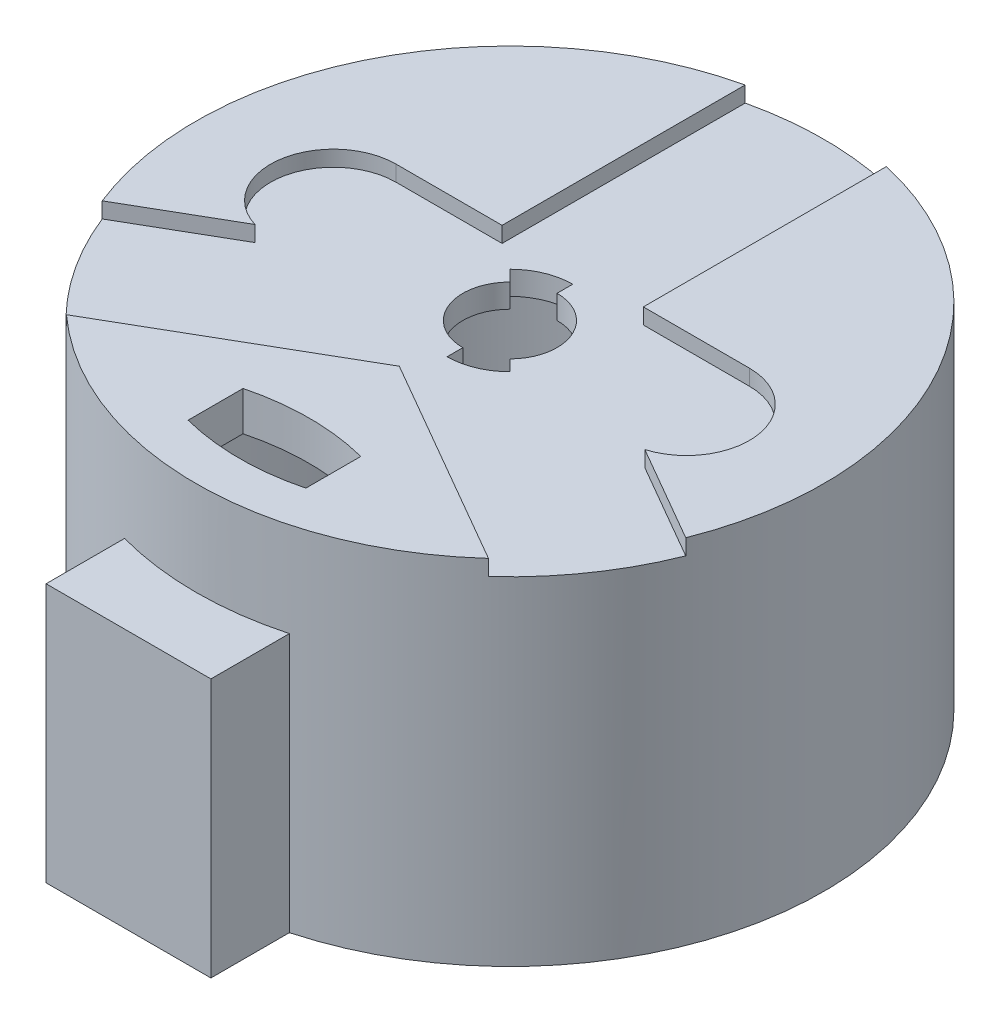
from build123d import *
from build123d.topology import SkipClean

# Parameters (mm, degrees)
BOSS_EXTRUDE1_DEPTH     = 5
BOSS_EXTRUDE1_2_DEPTH   = 5
BOSS_EXTRUDE1_3_DEPTH   = 5
BOSS_EXTRUDE2_DEPTH     = 3
SKETCH2_R               = 40
SKETCH2_R_2             = 35
BOSS_EXTRUDE3_DEPTH     = 40
CUT_EXTRUDE1_DEPTH      = 1
CUT_EXTRUDE1_DEPTH_BACK = 46
SKETCH5_R               = 6
CUT_EXTRUDE4_DEPTH      = 3
CUT_EXTRUDE4_DEPTH_BACK = 44
CUT_EXTRUDE6_DEPTH      = 2
BOSS_EXTRUDE6_DEPTH     = 30
CUT_EXTRUDE7_DEPTH      = 30
BOSS_EXTRUDE7_START     = -30
BOSS_EXTRUDE7_DEPTH     = 3


with BuildPart() as part:
    # Sketch1 → Boss-Extrude1 (new body)
    with BuildSketch(Plane(origin=(0, 0, 0), x_dir=(1, 0, 0), z_dir=(0, 1, 0))):
        with BuildLine():
            ThreePointArc((-26.885901745, -29.616689338), (0, -40), (26.885901745, -29.616689338))
            Line((26.885901745, -29.616689338), (0, -14.094106728))
            Line((0, -14.094106728), (-26.885901745, -29.616689338))
        make_face()
    extrude(amount=BOSS_EXTRUDE1_DEPTH)



with BuildPart() as body_2:
    # Sketch1 → Boss-Extrude1 2 (new body)
    with BuildSketch(Plane(origin=(0, 0, 0), x_dir=(1, 0, 0), z_dir=(0, 1, 0))):
        with BuildLine():
            ThreePointArc((-9, 38.97435054), (-35.427756972, 18.570784472), (-37.172733345, -14.771184641))
            Line((-37.172733345, -14.771184641), (-9, 1.49435054))
            Line((-9, 1.49435054), (-9, 38.97435054))
        make_face()
    extrude(amount=BOSS_EXTRUDE1_2_DEPTH)


with BuildPart() as body_3:
    # Sketch1 → Boss-Extrude1 3 (new body)
    with BuildSketch(Plane(origin=(0, 0, 0), x_dir=(1, 0, 0), z_dir=(0, 1, 0))):
        with BuildLine():
            Line((9, 1.49435054), (37.172733345, -14.771184641))
            ThreePointArc((37.172733345, -14.771184641), (39.286825615, -7.519663098), (40, 0))
            ThreePointArc((40, 0), (31.304951685, 24.899799196), (9, 38.97435054))
            Line((9, 38.97435054), (9, 1.49435054))
        make_face()
    extrude(amount=BOSS_EXTRUDE1_3_DEPTH)


with BuildPart() as part_1:
    add(part.part)

    add(body_2.part)  # Boss-Extrude2 merges body 2

    add(body_3.part)  # Boss-Extrude2 merges body 3
    # Sketch1_3 → Boss-Extrude2 (add)
    with BuildSketch(Plane(origin=(0, 0, 0), x_dir=(1, 0, 0), z_dir=(0, 1, 0))):
        with BuildLine():
            Line((0, -14.094106728), (26.885901745, -29.616689338))
            ThreePointArc((26.885901745, -29.616689338), (32.878175661, -22.782132586), (37.172733345, -14.771184641))
            Line((37.172733345, -14.771184641), (9, 1.49435054))
            Line((9, 1.49435054), (9, 38.97435054))
            ThreePointArc((9, 38.97435054), (0, 40), (-9, 38.97435054))
            Line((-9, 38.97435054), (-9, 1.49435054))
            Line((-9, 1.49435054), (-37.172733345, -14.771184641))
            ThreePointArc((-37.172733345, -14.771184641), (-32.878175661, -22.782132586), (-26.885901745, -29.616689338))
            Line((-26.885901745, -29.616689338), (0, -14.094106728))
        make_face()
    extrude(amount=BOSS_EXTRUDE2_DEPTH)

    # Sketch2 → Boss-Extrude3 (add)
    with SkipClean():  # keep this step's faces unmerged: merging them makes the solid invalid here
        with BuildSketch(Plane.XZ):
            with Locations(Location((0, 0, 0), (0, 0, 270))):  # turned: the seam where the file's is
                Circle(SKETCH2_R)
            with Locations(Location((0, 0, 0), (0, 0, 270))):  # turned: the seam where the file's is
                Circle(SKETCH2_R_2, mode=Mode.SUBTRACT)
        extrude(amount=BOSS_EXTRUDE3_DEPTH)

    # Sketch3 → Cut-Extrude1 (cut, two sides)
    with SkipClean():  # keep this step's faces unmerged: merging them makes the solid invalid here
        with BuildSketch(Plane(origin=(0, 5, 0), x_dir=(1, 0, 0), z_dir=(0, 1, 0))) as cut_extrude1_sk:
            with BuildLine():
                Line((-7.5, -26.5), (-7.5, -33.5))
                ThreePointArc((-7.5, -33.5), (0, -34.452624903), (7.5, -33.5))
                Line((7.5, -33.5), (7.5, -26.5))
                ThreePointArc((7.5, -26.5), (0, -25.547375097), (-7.5, -26.5))
            make_face()
        extrude(amount=CUT_EXTRUDE1_DEPTH, mode=Mode.SUBTRACT)
        extrude(cut_extrude1_sk.sketch, amount=-CUT_EXTRUDE1_DEPTH_BACK, mode=Mode.SUBTRACT)

    # Sketch5 → Cut-Extrude4 (cut, two sides)
    with SkipClean():  # keep this step's faces unmerged: merging them makes the solid invalid here
        with BuildSketch(Plane(origin=(0, 3, 0), x_dir=(1, 0, 0), z_dir=(0, 1, 0))) as cut_extrude4_sk:
            Circle(SKETCH5_R)
            with BuildLine():
                ThreePointArc((-4.242640687, 4.242640687), (-2.296100594, 5.543277195), (0, 6))
                Line((0, 6), (0, 8))
                ThreePointArc((0, 8), (-3.061467459, 7.39103626), (-5.656854249, 5.656854249))
                Line((-5.656854249, 5.656854249), (-4.242640687, 4.242640687))
            make_face()
            with BuildLine():
                Line((5.656854249, -5.656854249), (4.242640687, -4.242640687))
                ThreePointArc((4.242640687, -4.242640687), (2.296100594, -5.543277195), (0, -6))
                Line((0, -6), (0, -8))
                ThreePointArc((0, -8), (3.061467459, -7.39103626), (5.656854249, -5.656854249))
            make_face()
        extrude(amount=CUT_EXTRUDE4_DEPTH, mode=Mode.SUBTRACT)
        extrude(cut_extrude4_sk.sketch, amount=-CUT_EXTRUDE4_DEPTH_BACK, mode=Mode.SUBTRACT)

    # Sketch17 → Cut-Extrude6 (cut)
    with SkipClean():  # keep this step's faces unmerged: merging them makes the solid invalid here
        with BuildSketch(Plane(origin=(0, 5, 0), x_dir=(1, 0, 0), z_dir=(0, 1, 0))):
            with BuildLine():
                Line((-22.5, 8), (22.5, 8))
                ThreePointArc((22.5, 8), (30.5, 0), (22.5, -8))
                Line((22.5, -8), (-22.5, -8))
                ThreePointArc((-22.5, -8), (-30.5, 0), (-22.5, 8))
            make_face()
        extrude(amount=-CUT_EXTRUDE6_DEPTH, mode=Mode.SUBTRACT)

    # Sketch19 → Boss-Extrude6 (add)
    with SkipClean():  # keep this step's faces unmerged: merging them makes the solid invalid here
        with BuildSketch(Plane.XZ.offset(40)):
            with BuildLine():
                Line((-10.5, 48.597279697), (-10.5, 38.597279697))
                ThreePointArc((-10.5, 38.597279697), (-6.780749573, 39.421078565), (-3, 39.88734135))
                Line((-3, 39.88734135), (-3, 40.597279697))
                Line((-3, 40.597279697), (-8.5, 40.597279697))
                Line((-8.5, 40.597279697), (-8.5, 46.597279697))
                Line((-8.5, 46.597279697), (8.5, 46.597279697))
                Line((8.5, 46.597279697), (8.5, 40.597279697))
                Line((8.5, 40.597279697), (3, 40.597279697))
                Line((3, 40.597279697), (3, 39.88734135))
                ThreePointArc((3, 39.88734135), (6.780749573, 39.421078565), (10.5, 38.597279697))
                Line((10.5, 38.597279697), (10.5, 48.597279697))
                Line((10.5, 48.597279697), (-10.5, 48.597279697))
            make_face()
            with BuildLine():
                ThreePointArc((-3, 39.88734135), (-6.780749573, 39.421078565), (-10.5, 38.597279697))
                Line((-10.5, 38.597279697), (-5, 38.597279697))
                Line((-5, 38.597279697), (-5, 34.641016151))
                ThreePointArc((-5, 34.641016151), (-4.001655305, 34.770486836), (-3, 34.871191548))
                Line((-3, 34.871191548), (-3, 39.88734135))
            make_face()
            with BuildLine():
                Line((5, 38.597279697), (10.5, 38.597279697))
                ThreePointArc((10.5, 38.597279697), (6.780749573, 39.421078565), (3, 39.88734135))
                Line((3, 39.88734135), (3, 34.871191548))
                ThreePointArc((3, 34.871191548), (4.001655305, 34.770486836), (5, 34.641016151))
                Line((5, 34.641016151), (5, 38.597279697))
            make_face()
        extrude(amount=-BOSS_EXTRUDE6_DEPTH)

    # Sketch19_3 → Cut-Extrude7 (cut)
    with SkipClean():  # keep this step's faces unmerged: merging them makes the solid invalid here
        with BuildSketch(Plane.XZ.offset(40)):
            with BuildLine():
                ThreePointArc((2.5, 39.921798557), (0, 40), (-2.5, 39.921798557))
                Line((-2.5, 39.921798557), (-2.5, 34.910600109))
                ThreePointArc((-2.5, 34.910600109), (0, 35), (2.5, 34.910600109))
                Line((2.5, 34.910600109), (2.5, 39.921798557))
            make_face()
            with BuildLine():
                ThreePointArc((-2.5, 39.921798557), (-2.750053968, 39.905353064), (-3, 39.88734135))
                Line((-3, 39.88734135), (-3, 34.871191548))
                ThreePointArc((-3, 34.871191548), (-2.750070592, 34.891791466), (-2.5, 34.910600109))
                Line((-2.5, 34.910600109), (-2.5, 39.921798557))
            make_face()
            with BuildLine():
                ThreePointArc((3, 39.88734135), (2.750053968, 39.905353064), (2.5, 39.921798557))
                Line((2.5, 39.921798557), (2.5, 34.910600109))
                ThreePointArc((2.5, 34.910600109), (2.750070592, 34.891791466), (3, 34.871191548))
                Line((3, 34.871191548), (3, 39.88734135))
            make_face()
        extrude(amount=-CUT_EXTRUDE7_DEPTH, mode=Mode.SUBTRACT)

    # Sketch19_4 → Boss-Extrude7 (add)
    with SkipClean():  # keep this step's faces unmerged: merging them makes the solid invalid here
        with BuildSketch(Plane.XZ.offset(40).offset(BOSS_EXTRUDE7_START)):
            with BuildLine():
                Line((-10.5, 48.597279697), (-10.5, 38.597279697))
                ThreePointArc((-10.5, 38.597279697), (-6.780749573, 39.421078565), (-3, 39.88734135))
                Line((-3, 39.88734135), (-3, 40.597279697))
                Line((-3, 40.597279697), (-8.5, 40.597279697))
                Line((-8.5, 40.597279697), (-8.5, 46.597279697))
                Line((-8.5, 46.597279697), (8.5, 46.597279697))
                Line((8.5, 46.597279697), (8.5, 40.597279697))
                Line((8.5, 40.597279697), (3, 40.597279697))
                Line((3, 40.597279697), (3, 39.88734135))
                ThreePointArc((3, 39.88734135), (6.780749573, 39.421078565), (10.5, 38.597279697))
                Line((10.5, 38.597279697), (10.5, 48.597279697))
                Line((10.5, 48.597279697), (-10.5, 48.597279697))
            make_face()
            with BuildLine():
                Line((-3, 40.597279697), (-3, 39.88734135))
                ThreePointArc((-3, 39.88734135), (-2.750053968, 39.905353064), (-2.5, 39.921798557))
                Line((-2.5, 39.921798557), (-2.5, 41.097279697))
                Line((-2.5, 41.097279697), (-8, 41.097279697))
                Line((-8, 41.097279697), (-8, 46.097279697))
                Line((-8, 46.097279697), (8, 46.097279697))
                Line((8, 46.097279697), (8, 41.097279697))
                Line((8, 41.097279697), (2.5, 41.097279697))
                Line((2.5, 41.097279697), (2.5, 39.921798557))
                ThreePointArc((2.5, 39.921798557), (2.750053968, 39.905353064), (3, 39.88734135))
                Line((3, 39.88734135), (3, 40.597279697))
                Line((3, 40.597279697), (8.5, 40.597279697))
                Line((8.5, 40.597279697), (8.5, 46.597279697))
                Line((8.5, 46.597279697), (-8.5, 46.597279697))
                Line((-8.5, 46.597279697), (-8.5, 40.597279697))
                Line((-8.5, 40.597279697), (-3, 40.597279697))
            make_face()
            with BuildLine():
                Line((-2.5, 41.097279697), (-2.5, 39.921798557))
                ThreePointArc((-2.5, 39.921798557), (0, 40), (2.5, 39.921798557))
                Line((2.5, 39.921798557), (2.5, 41.097279697))
                Line((2.5, 41.097279697), (8, 41.097279697))
                Line((8, 41.097279697), (8, 46.097279697))
                Line((8, 46.097279697), (-8, 46.097279697))
                Line((-8, 46.097279697), (-8, 41.097279697))
                Line((-8, 41.097279697), (-2.5, 41.097279697))
            make_face()
        extrude(amount=-BOSS_EXTRUDE7_DEPTH)


solid = part_1.part
